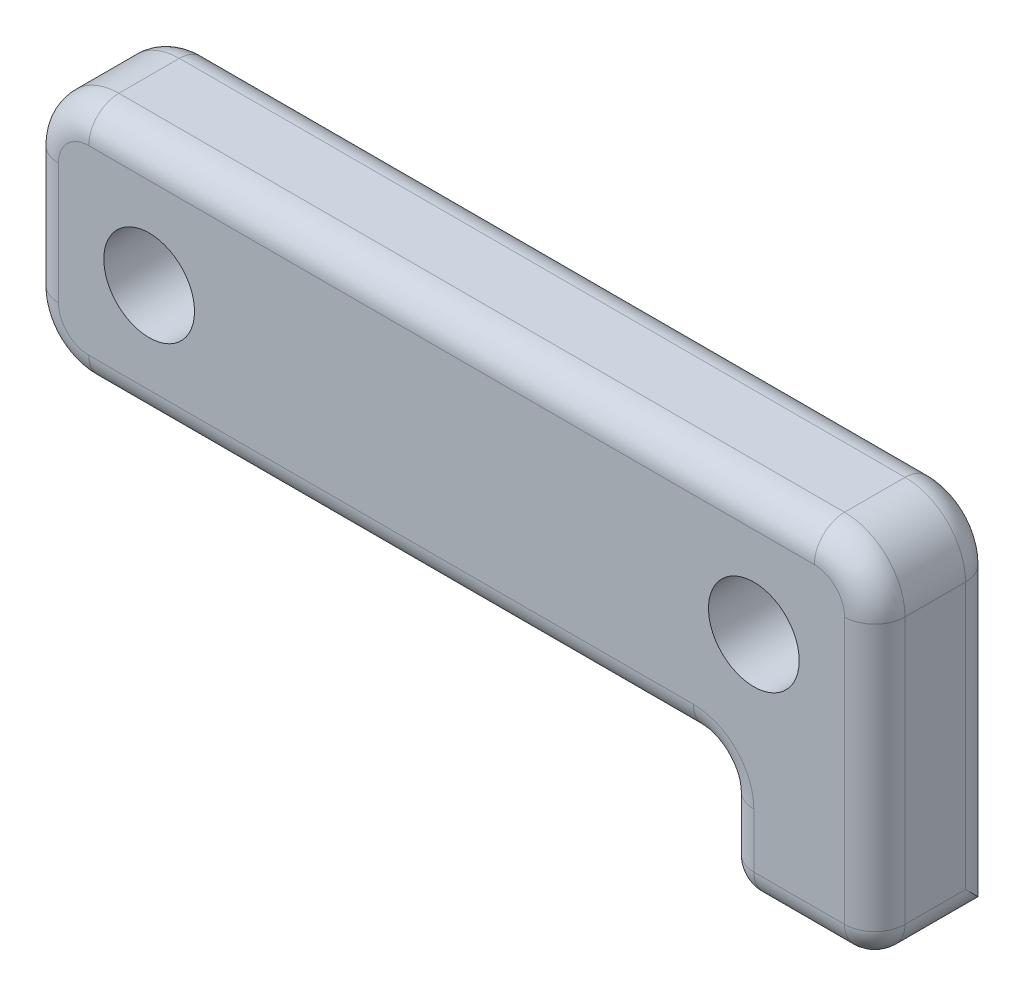
from build123d import *

# Parameters (mm, degrees)
SKETCH1_W      = 2.7
SKETCH1_H      = 3.805531959
SKETCH1_W_2    = 1.7
SKETCH1_R      = 1.5
SKETCH1_R_2    = 2.3
EXTRUDE1_DEPTH = 2
EXTRUDE2_START = -2
SKETCH1_4_R    = 2.3
SKETCH1_4_R_2  = 1.5
EXTRUDE2_DEPTH = 1
FILLET1_R      = 1


with BuildPart() as part:
    # Sketch1 → Extrude1 (new, symmetric)
    with BuildSketch(Plane.XY):
        with BuildLine():
            Line((12.3, -4), (12.3, -3.977371993))
            ThreePointArc((12.3, -3.977371993), (12.150426084, -3.994334975), (12, -4))
            Line((12, -4), (12.3, -4))
        make_face()
        with BuildLine():
            Line((14, -4), (14, -2))
            ThreePointArc((14, -2), (13.516575089, -3.303840481), (12.3, -3.977371993))
            Line((12.3, -3.977371993), (12.3, -4))
            Line((12.3, -4), (14, -4))
        make_face()
        with Locations((10.35, -5.902765979)):
            Rectangle(SKETCH1_W, SKETCH1_H)
        Polygon((12, -4), (11.7, -4), (11.7, -7.805531959), (12.3, -7.805531959), (12.3, -4), align=None)
        with Locations((13.15, -5.902765979)):
            Rectangle(SKETCH1_W_2, SKETCH1_H)
        with BuildLine():
            ThreePointArc((12, -4), (12.150426084, -3.994334975), (12.3, -3.977371993))
            Line((12.3, -3.977371993), (12.3, 0))
            ThreePointArc((12.3, 0), (12.144761059, -0.830662386), (11.7, -1.549193338))
            Line((11.7, -1.549193338), (11.7, -4))
            Line((11.7, -4), (12, -4))
        make_face()
        with BuildLine():
            Line((12, 4), (-12, 4))
            ThreePointArc((-12, 4), (-13.414213562, 3.414213562), (-14, 2))
            Line((-14, 2), (-14, -2))
            ThreePointArc((-14, -2), (-13.414213562, -3.414213562), (-12, -4))
            Line((-12, -4), (9, -4))
            Line((9, -4), (11.7, -4))
            Line((11.7, -4), (11.7, -1.549193338))
            ThreePointArc((11.7, -1.549193338), (7.855238941, 0.830662386), (12.3, 0))
            Line((12.3, 0), (12.3, -3.977371993))
            ThreePointArc((12.3, -3.977371993), (13.516575089, -3.303840481), (14, -2))
            Line((14, -2), (14, 2))
            ThreePointArc((14, 2), (13.414213562, 3.414213562), (12, 4))
        make_face()
        with Locations((-10, 0)):
            Circle(SKETCH1_R, mode=Mode.SUBTRACT)
        with Locations((10, 0)):
            Circle(SKETCH1_R_2)
        with Locations((10, 0)):
            Circle(SKETCH1_R, mode=Mode.SUBTRACT)
    extrude(amount=EXTRUDE1_DEPTH, both=True)

    # Sketch1_4 → Extrude2 (cut)
    with BuildSketch(Plane.XY.offset(EXTRUDE2_START)):
        with BuildLine():
            Line((12.3, -4), (12.3, -3.977371993))
            ThreePointArc((12.3, -3.977371993), (12.150426084, -3.994334975), (12, -4))
            Line((12, -4), (12.3, -4))
        make_face()
        with Locations((10, 0)):
            Circle(SKETCH1_4_R)
        with Locations((10, 0)):
            Circle(SKETCH1_4_R_2, mode=Mode.SUBTRACT)
        with BuildLine():
            ThreePointArc((12, -4), (12.150426084, -3.994334975), (12.3, -3.977371993))
            Line((12.3, -3.977371993), (12.3, 0))
            ThreePointArc((12.3, 0), (12.144761059, -0.830662386), (11.7, -1.549193338))
            Line((11.7, -1.549193338), (11.7, -4))
            Line((11.7, -4), (12, -4))
        make_face()
        Polygon((12, -4), (11.7, -4), (11.7, -7.805531959), (12.3, -7.805531959), (12.3, -4), align=None)
    extrude(amount=EXTRUDE2_DEPTH, mode=Mode.SUBTRACT)

    # Fillet1
    fillet1_edges = [part.edges().sort_by_distance(p)[0] for p in [
        (9, -5.902765979, 2),
        (-13.414213562, -3.414213562, -2),
        (-14, 0, -2),
        (11.5, -7.805531959, 2),
        (-13.414213562, 3.414213562, -2),
        (0, 4, -2),
        (13.414213562, 3.414213562, -2),
        (14, -2.902765979, -2),
        (9, -5.902765979, -2),
        (-1.5, -4, -2),
        (14, -2.902765979, 2),
        (14, -7.805531959, 0),
        (9, -7.805531959, 0),
        (9, -4, 0),
        (13.414213562, 3.414213562, 2),
        (0, 4, 2),
        (-13.414213562, 3.414213562, 2),
        (-14, 0, 2),
        (-13.414213562, -3.414213562, 2),
        (-1.5, -4, 2),
    ]]
    fillet(fillet1_edges, radius=FILLET1_R)


solid = part.part
